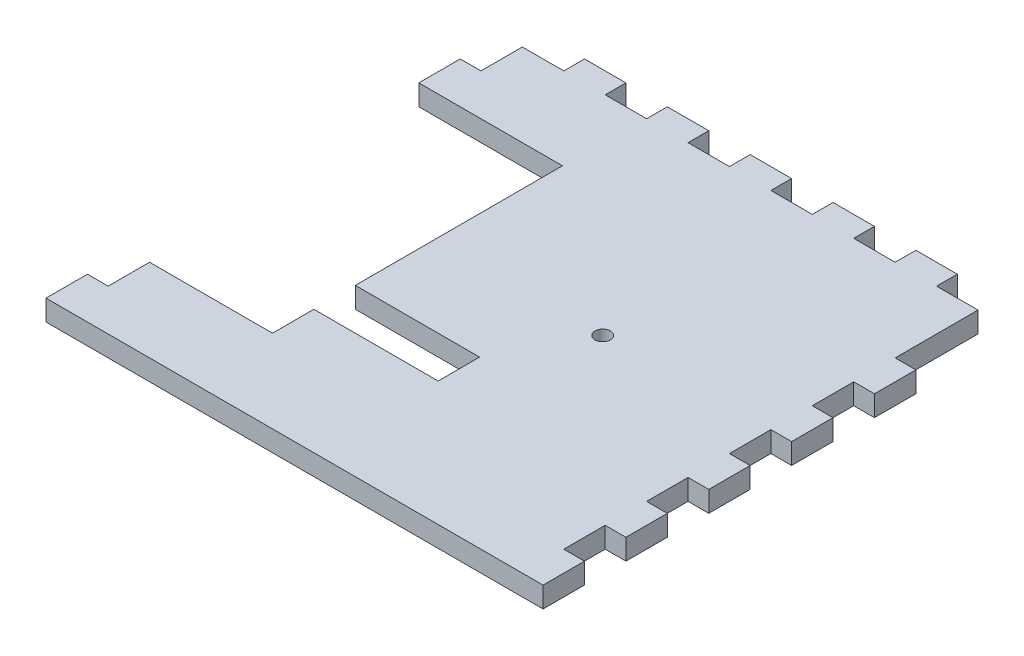
from build123d import *

# Parameters (mm, degrees)
SKETCH1_W               = 279.4
SKETCH1_H               = 279.4
BOSS_EXTRUDE1_DEPTH     = 12.7
SKETCH2_W               = 25.4
SKETCH2_H               = 12.7
BOSS_EXTRUDE2_DEPTH     = 12.7
LPATTERN1_COUNT         = 5
LPATTERN1_PITCH         = 50.8
MIRROR1_COPY_1_SKETCH_W = 25.4
MIRROR1_COPY_1_SKETCH_H = 12.7
MIRROR1_COPY_1_DEPTH    = 12.7
MIRROR1_COPY_2_SKETCH_W = 25.4
MIRROR1_COPY_2_SKETCH_H = 12.7
MIRROR1_COPY_2_DEPTH    = 12.7
MIRROR1_COPY_3_SKETCH_W = 25.4
MIRROR1_COPY_3_SKETCH_H = 12.7
MIRROR1_COPY_3_DEPTH    = 12.7
MIRROR1_COPY_4_SKETCH_W = 25.4
MIRROR1_COPY_4_SKETCH_H = 12.7
MIRROR1_COPY_4_DEPTH    = 12.7
SKETCH3_W               = 25.4
SKETCH3_H               = 12.7
BOSS_EXTRUDE3_DEPTH     = 12.7
LPATTERN2_COUNT         = 5
LPATTERN2_PITCH         = 50.8
SKETCH6_R               = 4.7625
CUT_EXTRUDE1_DEPTH      = 13.7
SKETCH8_W               = 88.066093183
SKETCH8_H               = 177.8
CUT_EXTRUDE3_DEPTH      = 13.7
SKETCH9_W               = 25.4
SKETCH9_H               = 12.7
BOSS_EXTRUDE4_DEPTH     = 12.7
SKETCH11_W              = 25.4
SKETCH11_H              = 12.7
CUT_EXTRUDE4_DEPTH      = 76.2


with BuildPart() as part:
    # Sketch1 → Boss-Extrude1 (new body)
    with BuildSketch(Plane(origin=(0, 0, 0), x_dir=(1, 0, 0), z_dir=(0, 1, 0))):
        Rectangle(SKETCH1_W, SKETCH1_H)
    extrude(amount=BOSS_EXTRUDE1_DEPTH)

    # Sketch2 → Boss-Extrude2 (add)
    with BuildSketch(Plane(origin=(139.7, 0, 0), x_dir=(0, 0, -1), z_dir=(1, 0, 0))):
        with Locations((-127, 6.35)):
            Rectangle(SKETCH2_W, SKETCH2_H)
    boss_extrude2 = extrude(amount=BOSS_EXTRUDE2_DEPTH)

    # LPattern1: Boss-Extrude2 ×5
    with Locations(*[(0, 0, -i * LPATTERN1_PITCH) for i in range(1, LPATTERN1_COUNT)]):
        add(boss_extrude2)

    # Mirror1: Boss-Extrude2 across plane
    add(boss_extrude2.mirror(Plane(origin=(0, 0, 0), x_dir=(0, 0, 1), z_dir=(1, 0, 0))))

    # Mirror1 copy 1 sketch → Mirror1 copy 1 (add)
    with BuildSketch(Plane(origin=(-139.7, 0, -50.8), x_dir=(0, 0, -1), z_dir=(-1, 0, 0))):
        with Locations((-127, -6.35)):
            Rectangle(MIRROR1_COPY_1_SKETCH_W, MIRROR1_COPY_1_SKETCH_H)
    extrude(amount=MIRROR1_COPY_1_DEPTH)

    # Mirror1 copy 2 sketch → Mirror1 copy 2 (add)
    with BuildSketch(Plane(origin=(-139.7, 0, -101.6), x_dir=(0, 0, -1), z_dir=(-1, 0, 0))):
        with Locations((-127, -6.35)):
            Rectangle(MIRROR1_COPY_2_SKETCH_W, MIRROR1_COPY_2_SKETCH_H)
    extrude(amount=MIRROR1_COPY_2_DEPTH)

    # Mirror1 copy 3 sketch → Mirror1 copy 3 (add)
    with BuildSketch(Plane(origin=(-139.7, 0, -152.4), x_dir=(0, 0, -1), z_dir=(-1, 0, 0))):
        with Locations((-127, -6.35)):
            Rectangle(MIRROR1_COPY_3_SKETCH_W, MIRROR1_COPY_3_SKETCH_H)
    extrude(amount=MIRROR1_COPY_3_DEPTH)

    # Mirror1 copy 4 sketch → Mirror1 copy 4 (add)
    with BuildSketch(Plane(origin=(-139.7, 0, -203.2), x_dir=(0, 0, -1), z_dir=(-1, 0, 0))):
        with Locations((-127, -6.35)):
            Rectangle(MIRROR1_COPY_4_SKETCH_W, MIRROR1_COPY_4_SKETCH_H)
    extrude(amount=MIRROR1_COPY_4_DEPTH)

    # Sketch3 → Boss-Extrude3 (add)
    with BuildSketch(Plane(origin=(0, 0, -139.7), x_dir=(-1, 0, 0), z_dir=(0, 0, -1))):
        with Locations((-101.6, 6.35)):
            Rectangle(SKETCH3_W, SKETCH3_H)
    boss_extrude3 = extrude(amount=BOSS_EXTRUDE3_DEPTH)

    # LPattern2: Boss-Extrude3 ×5
    with Locations(*[(-i * LPATTERN2_PITCH, 0, 0) for i in range(1, LPATTERN2_COUNT)]):
        add(boss_extrude3)

    # Sketch6 → Cut-Extrude1 (cut, through all)
    with BuildSketch(Plane(origin=(0, 12.7, 0), x_dir=(1, 0, 0), z_dir=(0, 1, 0))):
        with Locations((38.1, 11.176)):
            Circle(SKETCH6_R)
    extrude(amount=-CUT_EXTRUDE1_DEPTH, mode=Mode.SUBTRACT)

    # Sketch8 → Cut-Extrude3 (cut, through all)
    with BuildSketch(Plane(origin=(0, 12.7, 0), x_dir=(1, 0, 0), z_dir=(0, 1, 0))):
        with Locations((-108.366953408, 0)):
            Rectangle(SKETCH8_W, SKETCH8_H)
    extrude(amount=-CUT_EXTRUDE3_DEPTH, mode=Mode.SUBTRACT)

    # Sketch9 → Boss-Extrude4 (add)
    with BuildSketch(Plane.ZY.offset(139.7)):
        with Locations((-101.6, 6.35)):
            Rectangle(SKETCH9_W, SKETCH9_H)
    extrude(amount=BOSS_EXTRUDE4_DEPTH)

    # Sketch11 → Cut-Extrude4 (cut)
    with BuildSketch(Plane.ZY.offset(64.333906817)):
        with Locations((50.8, 6.35)):
            Rectangle(SKETCH11_W, SKETCH11_H)
    extrude(amount=-CUT_EXTRUDE4_DEPTH, mode=Mode.SUBTRACT)


solid = part.part
